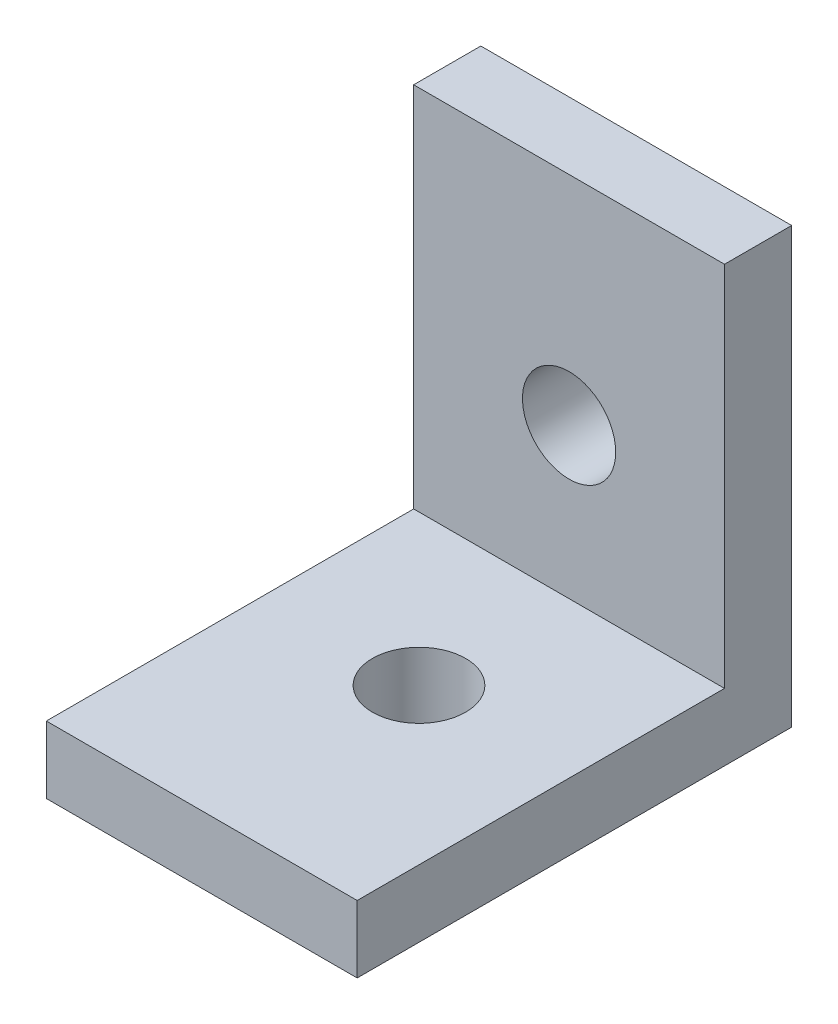
from build123d import *

# Parameters (mm, degrees)
SKETCH1_W           = 19.9898
SKETCH1_H           = 27.94
BOSS_EXTRUDE1_DEPTH = 4.318
SKETCH2_W           = 19.9898
SKETCH2_H           = 27.94
BOSS_EXTRUDE2_DEPTH = 4.318
SKETCH3_R           = 2.9972
CUT_EXTRUDE3_DEPTH  = 5.318
SKETCH4_R           = 2.9972
CUT_EXTRUDE4_DEPTH  = 5.318


with BuildPart() as part:
    # Sketch1 → Boss-Extrude1 (new body)
    with BuildSketch(Plane(origin=(0, 0, 0), x_dir=(1, 0, 0), z_dir=(0, 1, 0))):
        with Locations((9.9949, 13.97)):
            Rectangle(SKETCH1_W, SKETCH1_H)
    extrude(amount=BOSS_EXTRUDE1_DEPTH)

    # Sketch2 → Boss-Extrude2 (add)
    with BuildSketch(Plane(origin=(0, 0, -27.94), x_dir=(-1, 0, 0), z_dir=(0, 0, -1))):
        with Locations((-9.9949, 13.97)):
            Rectangle(SKETCH2_W, SKETCH2_H)
    extrude(amount=-BOSS_EXTRUDE2_DEPTH)

    # Sketch3 → Cut-Extrude3 (cut, through all)
    with BuildSketch(Plane(origin=(0, 4.318, 0), x_dir=(1, 0, 0), z_dir=(0, 1, 0))):
        with Locations((9.9949, 13.97)):
            Circle(SKETCH3_R)
    extrude(amount=-CUT_EXTRUDE3_DEPTH, mode=Mode.SUBTRACT)

    # Sketch4 → Cut-Extrude4 (cut, through all)
    with BuildSketch(Plane.XY.offset(-23.622)):
        with Locations((9.9949, 13.97)):
            Circle(SKETCH4_R)
    extrude(amount=-CUT_EXTRUDE4_DEPTH, mode=Mode.SUBTRACT)


solid = part.part
